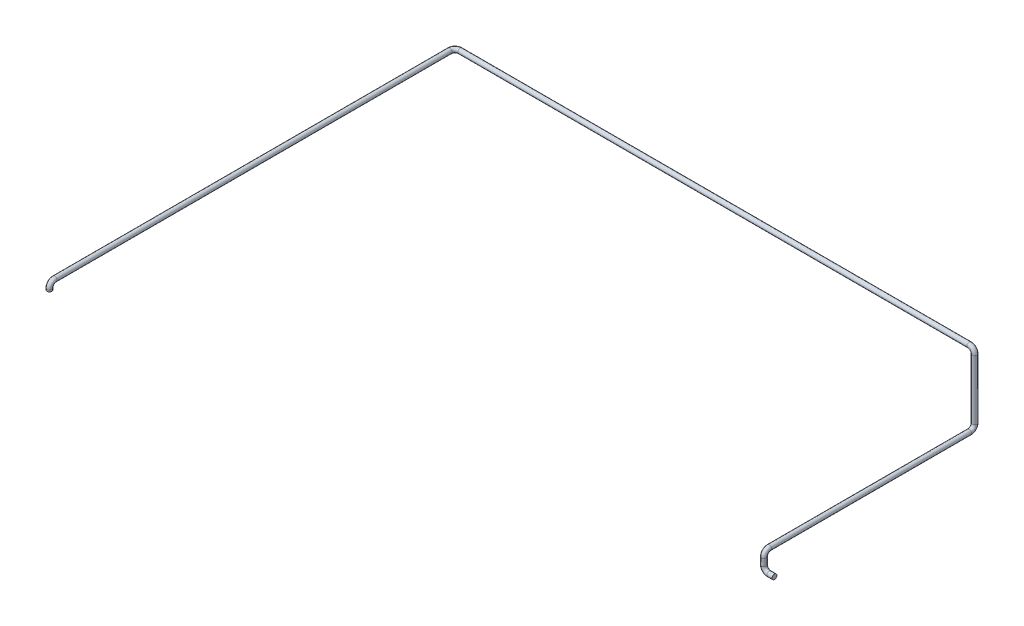
from build123d import *

# Parameters (mm, degrees)
CROQUIS1_R = 13.7


with BuildPart() as part:
    # Barrer1: sweep along a curve in space
    with BuildLine() as barrer1_path:
        Line((0, 0, 0), (-30, 0, 0))
        ThreePointArc((-30, 0, 0), (-51.213203436, 8.786796564, 0), (-60, 30, 0))
        Line((-60, 30, 0), (-60, 70, 0))
        ThreePointArc((-60, 70, 0), (-60, 91.213203436, -8.786796564), (-60, 100, -30))
        Line((-60, 100, -30), (-60, 100, -1170))
        ThreePointArc((-60, 130, -1200), (-60, 108.786796564, -1191.213203436), (-60, 100, -1170))
        Line((-60, 130, -1200), (-60, 470, -1200))
        ThreePointArc((-60, 470, -1200), (-68.786796564, 491.213203436, -1200), (-90, 500, -1200))
        Line((-90, 500, -1200), (-2990, 500, -1200))
        ThreePointArc((-2990, 500, -1200), (-3011.213203436, 500, -1191.213203436), (-3020, 500, -1170))
        Line((-3020, 500, -1170), (-3020, 500, 1080))
        ThreePointArc((-3020, 500, 1080), (-3020, 491.213203436, 1101.213203436), (-3020, 470, 1110))
        Line((-3020, 470, 1110), (-3020, 460, 1110))
    # Croquis1 → Barrer1 (sweep)
    with BuildSketch(Plane(origin=(0, 0, 0), x_dir=(0, 0, -1), z_dir=(1, 0, 0))):
        Circle(CROQUIS1_R)
    sweep(path=barrer1_path.line)


solid = part.part
